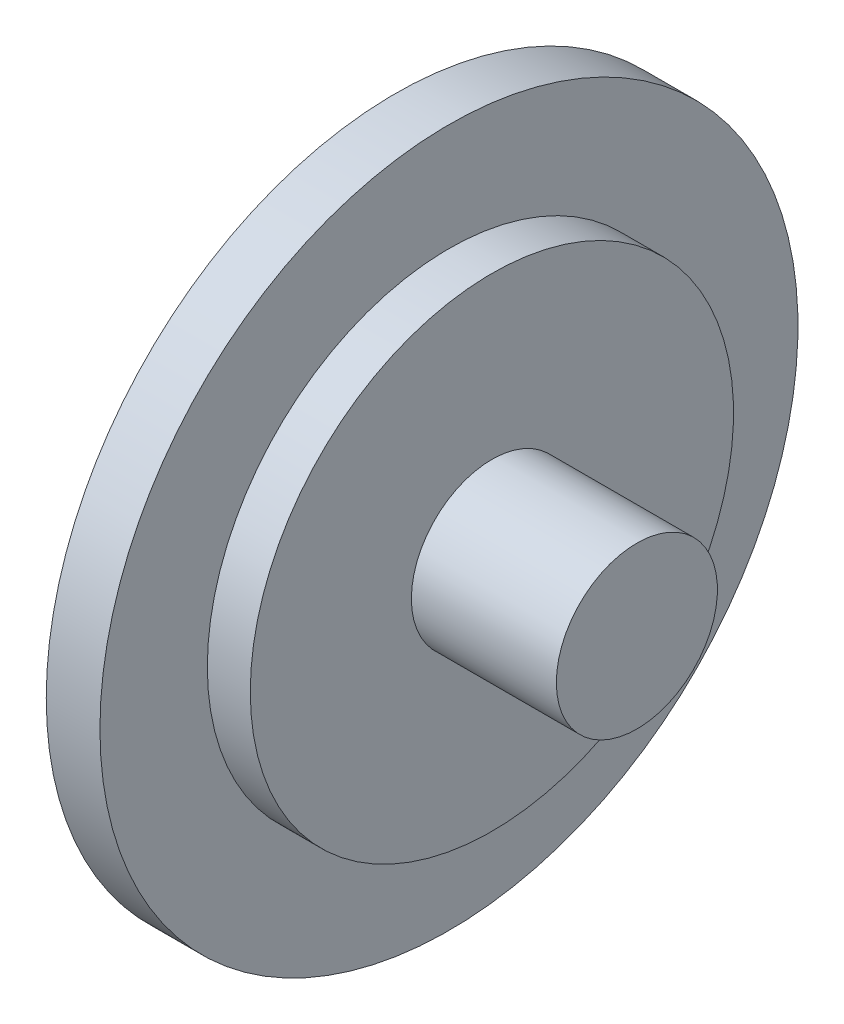
from build123d import *


with BuildPart() as part:
    # Sketch1 → Revolve1 (revolve)
    with BuildSketch(Plane.XY):
        Polygon((0, 0), (0, 13), (2, 13), (2, 9), (3.6, 9), (3.6, 3), (9, 3), (9, 0), align=None)
    revolve(axis=Axis((0, 0, 0), (1, 0, 0)))


solid = part.part
